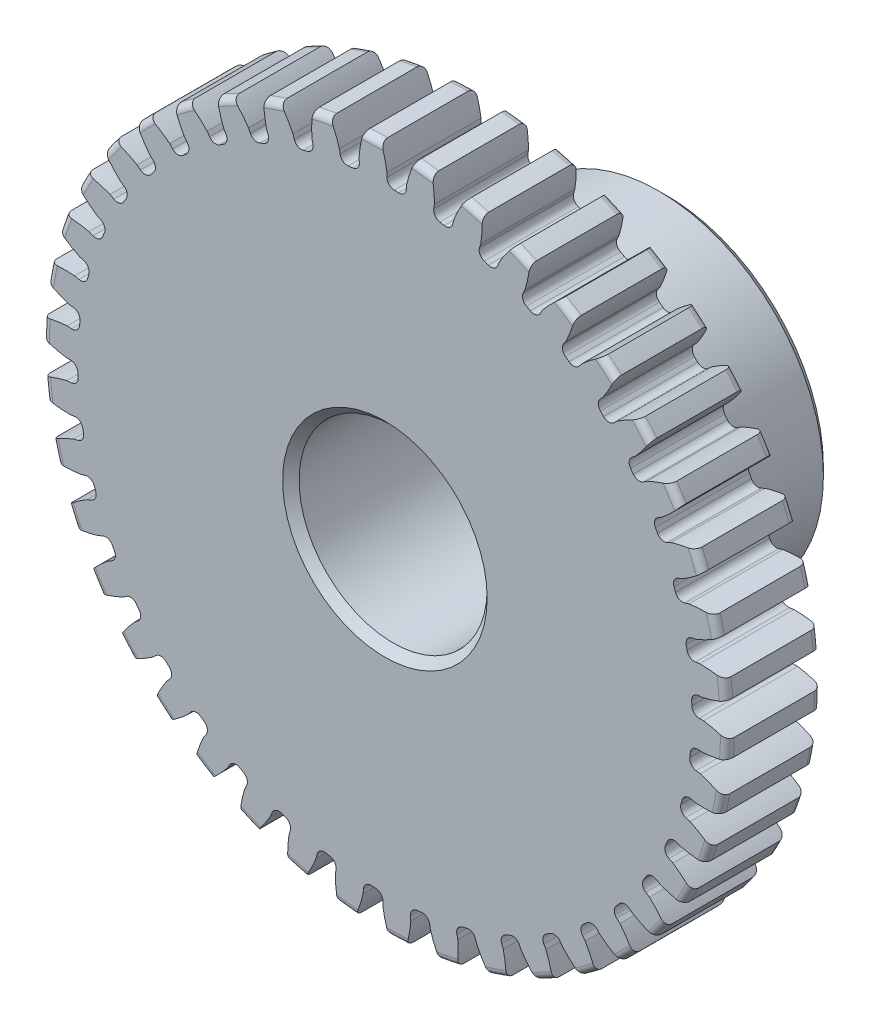
from build123d import *

# Parameters (mm, degrees)
SKETCH1_R                = 11.557
BOSS_EXTRUDE1_DEPTH      = 3.175
SKETCH2_W                = 6.35
SKETCH2_H                = 5.55625
REVOLVE1_ANGLE           = 360
FILLET2_R                = 0.23114
CUT_EXTRUDE1_DEPTH       = 10.525
FILLET1_R                = 0.2493645
CIRPATTERN1_COUNT        = 42
FILLET1_OF_CIRPATTERN1_R = 0.2493645
SKETCH5_R                = 3.175
CUT_EXTRUDE2_DEPTH       = 10.525
CHAMFER1_SIZE            = 0.2778125


with BuildPart() as part:
    # Sketch1 → Boss-Extrude1 (new body)
    with BuildSketch(Plane.XY):
        Circle(SKETCH1_R)
    extrude(amount=-BOSS_EXTRUDE1_DEPTH)

    # Sketch2 → Revolve1 (revolve, symmetric)
    with BuildSketch(Plane(origin=(0, 0, 0), x_dir=(0, 0, -1), z_dir=(1, 0, 0))) as revolve1_sk:
        with Locations((6.35, 2.778125)):
            Rectangle(SKETCH2_W, SKETCH2_H)
    revolve(axis=Axis((0, 0, -3.175), (0, 0, -1)), revolution_arc=REVOLVE1_ANGLE / 2)
    revolve(revolve1_sk.sketch, axis=Axis((0, 0, -3.175), (0, 0, 1)), revolution_arc=REVOLVE1_ANGLE / 2)

    # Fillet2
    fillet2_edges = [part.edges().sort_by_distance(p)[0] for p in [
        (-11.557, 0, 0),
        (-11.557, 0, -3.175),
        (0, -5.55625, -3.175),
    ]]
    fillet(fillet2_edges, radius=FILLET2_R)

    # Sketch4 → Cut-Extrude1 (cut, through all)
    with BuildSketch(Plane.XY):
        with BuildLine():
            Line((0.069806327, 10.758314184), (0.069806327, 10.366139962))
            ThreePointArc((0.069806327, 10.366139962), (0.387612048, 10.35912581), (0.705053284, 10.342370643))
            Line((0.705053284, 10.342370643), (0.734360569, 10.73344826))
            add(Edge.make_bspline(
                [(2.082393199, 12.940791778), (1.024987107, 12.003022413), (0.734360569, 10.73344826)],
                knots=[0, 0, 0, 1, 1, 1], degree=2))
            ThreePointArc((2.082393199, 12.940791778), (0.49009752, 13.098101302), (-1.10950154, 13.060224333))
            add(Edge.make_bspline(
                [(-1.10950154, 13.060224333), (-0.125131939, 12.046056933), (0.069806327, 10.758314184)],
                knots=[0, 0, 0, 1, 1, 1], degree=2))
        make_face()
    cut_extrude1 = extrude(amount=-CUT_EXTRUDE1_DEPTH, mode=Mode.SUBTRACT)

    # Fillet1
    fillet1_edges = [part.edges().sort_by_distance(p)[0] for p in [
        (0.705053284, 10.342370643, -1.5875),
        (0.069806327, 10.366139962, -1.5875),
    ]]
    fillet(fillet1_edges, radius=FILLET1_R)

    # CirPattern1: Cut-Extrude1 ×42 about axis
    cirpattern1_axis = Axis((0, 0, -3.175), (0, 0, 1))
    for i in range(1, CIRPATTERN1_COUNT):
        add(cut_extrude1.rotate(cirpattern1_axis, i * 360 / CIRPATTERN1_COUNT), mode=Mode.SUBTRACT)

    # Fillet1 of CirPattern1
    fillet1_of_cirpattern1_edges = [part.edges().sort_by_distance(p)[0] for p in [
        (-0.844271937, 10.331937647, -1.5875),
        (-1.475966343, 10.260762837, -1.5875),
        (-2.374737518, 10.090706237, -1.5875),
        (-2.988768365, 9.926177225, -1.5875),
        (-3.852155387, 9.624065124, -1.5875),
        (-4.434806239, 9.369857217, -1.5875),
        (-5.24352247, 8.9424383, -1.5875),
        (-5.781777871, 8.604230081, -1.5875),
        (-6.517757925, 8.061052181, -1.5875),
        (-6.999594139, 7.646398664, -1.5875),
        (-7.646397439, 6.999595477, -1.5875),
        (-8.061051041, 6.517759335, -1.5875),
        (-8.60422907, 5.781779376, -1.5875),
        (-8.942437383, 5.243524034, -1.5875),
        (-9.369856441, 4.434807878, -1.5875),
        (-9.624064451, 3.85215707, -1.5875),
        (-9.926176702, 2.988770101, -1.5875),
        (-10.090705822, 2.374739283, -1.5875),
        (-10.260762579, 1.475968138, -1.5875),
        (-10.331937499, 0.844273744, -1.5875),
        (-10.366139974, -0.069804514, -1.5875),
        (-10.342370766, -0.705051475, -1.5875),
        (-10.239954933, -1.614017849, -1.5875),
        (-10.12177256, -2.238627009, -1.5875),
        (-9.885026219, -3.122176691, -1.5875),
        (-9.675070681, -3.722195315, -1.5875),
        (-9.309282354, -4.560591266, -1.5875),
        (-9.01224371, -5.122615928, -1.5875),
        (-8.525584504, -5.897129768, -1.5875),
        (-8.148098107, -6.408605767, -1.5875),
        (-7.551439185, -7.101936136, -1.5875),
        (-7.101937457, -7.551437942, -1.5875),
        (-6.408607192, -8.148096986, -1.5875),
        (-5.89713126, -8.525583472, -1.5875),
        (-5.122617505, -9.012242814, -1.5875),
        (-4.560592895, -9.309281556, -1.5875),
        (-3.722197007, -9.67507003, -1.5875),
        (-3.122178421, -9.885025673, -1.5875),
        (-2.238628779, -10.121772168, -1.5875),
        (-1.61401964, -10.23995465, -1.5875),
        (-0.705053284, -10.342370643, -1.5875),
        (-0.069806327, -10.366139962, -1.5875),
        (0.844271937, -10.331937647, -1.5875),
        (1.475966343, -10.260762837, -1.5875),
        (2.374737518, -10.090706237, -1.5875),
        (2.988768365, -9.926177225, -1.5875),
        (3.852155387, -9.624065124, -1.5875),
        (4.434806239, -9.369857217, -1.5875),
        (5.24352247, -8.9424383, -1.5875),
        (5.781777871, -8.604230081, -1.5875),
        (6.517757925, -8.061052181, -1.5875),
        (6.999594139, -7.646398664, -1.5875),
        (7.646397439, -6.999595477, -1.5875),
        (8.061051041, -6.517759335, -1.5875),
        (8.60422907, -5.781779376, -1.5875),
        (8.942437383, -5.243524034, -1.5875),
        (9.369856441, -4.434807878, -1.5875),
        (9.624064451, -3.85215707, -1.5875),
        (9.926176702, -2.988770101, -1.5875),
        (10.090705822, -2.374739283, -1.5875),
        (10.260762579, -1.475968138, -1.5875),
        (10.331937499, -0.844273744, -1.5875),
        (10.366139974, 0.069804514, -1.5875),
        (10.342370766, 0.705051475, -1.5875),
        (10.239954933, 1.614017849, -1.5875),
        (10.12177256, 2.238627009, -1.5875),
        (9.885026219, 3.122176691, -1.5875),
        (9.675070681, 3.722195315, -1.5875),
        (9.309282354, 4.560591266, -1.5875),
        (9.01224371, 5.122615928, -1.5875),
        (8.525584504, 5.897129768, -1.5875),
        (8.148098107, 6.408605767, -1.5875),
        (7.551439185, 7.101936136, -1.5875),
        (7.101937457, 7.551437942, -1.5875),
        (6.408607192, 8.148096986, -1.5875),
        (5.89713126, 8.525583472, -1.5875),
        (5.122617505, 9.012242814, -1.5875),
        (4.560592895, 9.309281556, -1.5875),
        (3.722197007, 9.67507003, -1.5875),
        (3.122178421, 9.885025673, -1.5875),
        (2.238628779, 10.121772168, -1.5875),
        (1.61401964, 10.23995465, -1.5875),
    ]]
    fillet(fillet1_of_cirpattern1_edges, radius=FILLET1_OF_CIRPATTERN1_R)

    # Sketch5 → Cut-Extrude2 (cut, through all)
    with BuildSketch(Plane.XY):
        Circle(SKETCH5_R)
    extrude(amount=-CUT_EXTRUDE2_DEPTH, mode=Mode.SUBTRACT)

    # Chamfer1
    chamfer1_edges = [part.edges().sort_by_distance(p)[0] for p in [
        (-3.175, 0, -9.525),
        (-3.175, 0, 0),
        (0, -5.55625, -9.525),
    ]]
    chamfer(chamfer1_edges, length=CHAMFER1_SIZE)


solid = part.part
